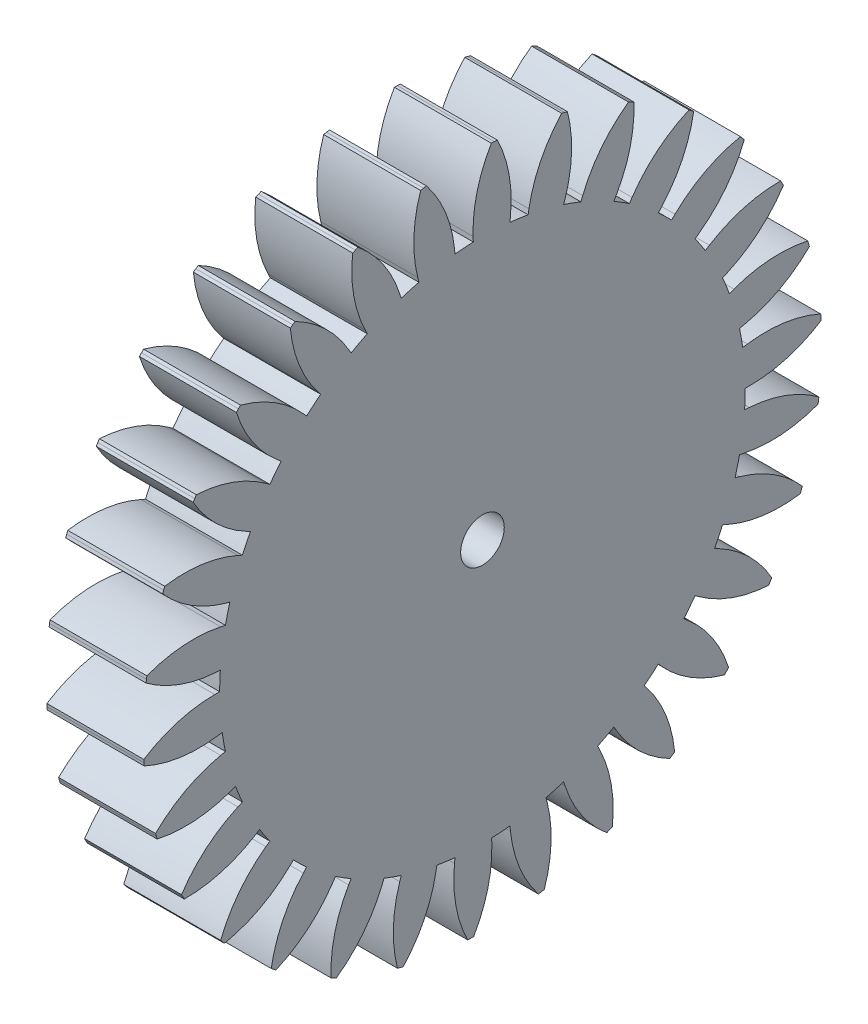
from build123d import *

# Parameters (mm, degrees)
SKETCH1_R           = 2.25
BOSS_EXTRUDE1_DEPTH = 10


with BuildPart() as part:
    # Sketch1 → Boss-Extrude1 (new body)
    with BuildSketch(Plane(origin=(0, 0, 0), x_dir=(0, 0, -1), z_dir=(1, 0, 0))):
        with BuildLine():
            Line((27.339383382, 3.842299761), (26.844249347, 3.77271321))
            ThreePointArc((26.844249347, 3.77271321), (26.696230764, 4.707265767), (26.515686935, 5.636083245))
            Line((26.515686935, 5.636083245), (27.004760736, 5.740039091))
            ThreePointArc((27.004760736, 5.740039091), (30.623978377, 7.066578698), (33.727065862, 9.353343163))
            Line((33.727065862, 9.353343163), (33.644159358, 9.647307454))
            Line((33.644159358, 9.647307454), (33.55869072, 9.940537065))
            ThreePointArc((33.55869072, 9.940537065), (29.715322743, 10.235437478), (25.943093221, 9.442513717))
            Line((25.943093221, 9.442513717), (25.47324691, 9.271503645))
            ThreePointArc((25.47324691, 9.271503645), (25.134158485, 10.154859192), (24.76444796, 11.025842608))
            Line((24.76444796, 11.025842608), (25.221220689, 11.229210929))
            ThreePointArc((25.221220689, 11.229210929), (28.485546649, 13.279240122), (31.045379161, 16.161201463))
            Line((31.045379161, 16.161201463), (30.90316575, 16.431504698))
            Line((30.90316575, 16.431504698), (30.758598943, 16.700556609))
            ThreePointArc((30.758598943, 16.700556609), (26.937904534, 16.189931607), (23.412965397, 14.630044514))
            Line((23.412965397, 14.630044514), (22.988941349, 14.365084882))
            ThreePointArc((22.988941349, 14.365084882), (22.473602874, 15.158636543), (21.930883777, 15.93371974))
            Line((21.930883777, 15.93371974), (22.335392274, 16.227612367))
            ThreePointArc((22.335392274, 16.227612367), (25.102159843, 18.911535033), (27.006860419, 22.26273771))
            Line((27.006860419, 22.26273771), (26.811555509, 22.497566339))
            Line((26.811555509, 22.497566339), (26.614208796, 22.730681692))
            ThreePointArc((26.614208796, 22.730681692), (22.983170634, 21.436848036), (19.859578637, 19.178172162))
            Line((19.859578637, 19.178172162), (19.499908737, 18.830842977))
            ThreePointArc((19.499908737, 18.830842977), (18.830842977, 19.499908737), (18.138834736, 20.145216862))
            Line((18.138834736, 20.145216862), (18.473400039, 20.516789275))
            ThreePointArc((18.473400039, 20.516789275), (20.621688199, 23.717305115), (21.788012282, 27.39128549))
            Line((21.788012282, 27.39128549), (21.548151636, 27.580376376))
            Line((21.548151636, 27.580376376), (21.306650015, 27.76736691))
            ThreePointArc((21.306650015, 27.76736691), (18.023961892, 25.74687134), (15.438232995, 22.888121661))
            Line((15.438232995, 22.888121661), (15.158636543, 22.473602874))
            ThreePointArc((15.158636543, 22.473602874), (14.365084882, 22.988941349), (13.554031577, 23.476271339))
            Line((13.554031577, 23.476271339), (13.804031577, 23.909284041))
            ThreePointArc((13.804031577, 23.909284041), (15.239949827, 27.486515155), (15.616923459, 31.322702656))
            Line((15.616923459, 31.322702656), (15.342990138, 31.45779162))
            Line((15.342990138, 31.45779162), (15.067888388, 31.590484952))
            ThreePointArc((15.067888388, 31.590484952), (12.277019527, 28.93163282), (10.342162489, 25.597750413))
            Line((10.342162489, 25.597750413), (10.154859192, 25.134158485))
            ThreePointArc((10.154859192, 25.134158485), (9.271503645, 25.47324691), (8.376852199, 25.781300107))
            Line((8.376852199, 25.781300107), (8.531360697, 26.256828365))
            ThreePointArc((8.531360697, 26.256828365), (9.192152518, 30.054432588), (8.763300142, 33.885167413))
            Line((8.763300142, 33.885167413), (8.467266346, 33.96035042))
            Line((8.467266346, 33.96035042), (8.170587735, 34.032947214))
            ThreePointArc((8.170587735, 34.032947214), (5.993512496, 30.851943116), (4.794089856, 27.18863464))
            Line((4.794089856, 27.18863464), (4.707265767, 26.696230764))
            ThreePointArc((4.707265767, 26.696230764), (3.77271321, 26.844249347), (2.833564184, 26.959562348))
            Line((2.833564184, 26.959562348), (2.885828415, 27.456823296))
            ThreePointArc((2.885828415, 27.456823296), (2.742614035, 31.3088271), (1.526678558, 34.966687755))
            Line((1.526678558, 34.966687755), (1.221482385, 34.978678946))
            Line((1.221482385, 34.978678946), (0.916193191, 34.988006374))
            ThreePointArc((0.916193191, 34.988006374), (-0.55193979, 31.423875454), (-0.963507509, 27.591245068))
            Line((-0.963507509, 27.591245068), (-0.946057761, 27.091549655))
            ThreePointArc((-0.946057761, 27.091549655), (-1.890962896, 27.042029275), (-2.833564184, 26.959562348))
            Line((-2.833564184, 26.959562348), (-2.885828415, 27.456823296))
            ThreePointArc((-2.885828415, 27.456823296), (-3.826789841, 31.194875631), (-5.776666205, 34.519996054))
            Line((-5.776666205, 34.519996054), (-6.077686218, 34.468271355))
            Line((-6.077686218, 34.468271355), (-6.378243392, 34.413921765))
            ThreePointArc((-6.378243392, 34.413921765), (-7.073269659, 30.622433646), (-6.678994972, 26.78798569))
            Line((-6.678994972, 26.78798569), (-6.558034024, 26.302837826))
            ThreePointArc((-6.558034024, 26.302837826), (-7.471994849, 26.057942762), (-8.376852199, 25.781300107))
            Line((-8.376852199, 25.781300107), (-8.531360697, 26.256828365))
            ThreePointArc((-8.531360697, 26.256828365), (-10.228944639, 29.717558407), (-12.827542935, 32.564614879))
            Line((-12.827542935, 32.564614879), (-13.11123077, 32.45143491))
            Line((-13.11123077, 32.45143491), (-13.393920133, 32.335783638))
            ThreePointArc((-13.393920133, 32.335783638), (-13.285463703, 28.482644546), (-12.102578306, 24.813962793))
            Line((-12.102578306, 24.813962793), (-11.883392732, 24.36456577))
            ThreePointArc((-11.883392732, 24.36456577), (-12.726464773, 23.934999109), (-13.554031577, 23.476271339))
            Line((-13.554031577, 23.476271339), (-13.804031577, 23.909284041))
            ThreePointArc((-13.804031577, 23.909284041), (-16.184045472, 26.94144128), (-19.317794486, 29.186003772))
            Line((-19.317794486, 29.186003772), (-19.571751621, 29.016315039))
            Line((-19.571751621, 29.016315039), (-19.824218292, 28.844416602))
            ThreePointArc((-19.824218292, 28.844416602), (-18.917019232, 25.098027203), (-16.997220893, 21.755450652))
            Line((-16.997220893, 21.755450652), (-16.689390155, 21.361445275))
            ThreePointArc((-16.689390155, 21.361445275), (-17.424727118, 20.765981143), (-18.138834736, 20.145216862))
            Line((-18.138834736, 20.145216862), (-18.473400039, 20.516789275))
            ThreePointArc((-18.473400039, 20.516789275), (-21.431825858, 22.98785389), (-24.96376572, 24.53182425))
            Line((-24.96376572, 24.53182425), (-25.176893012, 24.313042966))
            Line((-25.176893012, 24.313042966), (-25.388102985, 24.092410149))
            ThreePointArc((-25.388102985, 24.092410149), (-23.721810247, 20.616505638), (-21.149003365, 17.746120923))
            Line((-21.149003365, 17.746120923), (-20.765981143, 17.424727118))
            ThreePointArc((-20.765981143, 17.424727118), (-21.361445275, 16.689390155), (-21.930883777, 15.93371974))
            Line((-21.930883777, 15.93371974), (-22.335392274, 16.227612367))
            ThreePointArc((-22.335392274, 16.227612367), (-25.742932613, 18.029586977), (-29.518700603, 18.805486292))
            Line((-29.518700603, 18.805486292), (-29.681683365, 18.547174248))
            Line((-29.681683365, 18.547174248), (-29.842405752, 18.287449765))
            ThreePointArc((-29.842405752, 18.287449765), (-27.489844324, 15.233943848), (-24.376472906, 12.961200555))
            Line((-24.376472906, 12.961200555), (-23.934999109, 12.726464773))
            ThreePointArc((-23.934999109, 12.726464773), (-24.36456577, 11.883392732), (-24.76444796, 11.025842608))
            Line((-24.76444796, 11.025842608), (-25.221220689, 11.229210929))
            ThreePointArc((-25.221220689, 11.229210929), (-28.928949685, 12.283340598), (-32.783526624, 12.257258344))
            Line((-32.783526624, 12.257258344), (-32.889241728, 11.970705016))
            Line((-32.889241728, 11.970705016), (-32.992452188, 11.683240073))
            ThreePointArc((-32.992452188, 11.683240073), (-30.056440293, 9.185585611), (-26.53857361, 7.609813527))
            Line((-26.53857361, 7.609813527), (-26.057942762, 7.471994849))
            ThreePointArc((-26.057942762, 7.471994849), (-26.302837826, 6.558034024), (-26.515686935, 5.636083245))
            Line((-26.515686935, 5.636083245), (-27.004760736, 5.740039091))
            ThreePointArc((-27.004760736, 5.740039091), (-30.850632838, 6.000253292), (-34.615555218, 5.17332939))
            Line((-34.615555218, 5.17332939), (-34.659382406, 4.871058534))
            Line((-34.659382406, 4.871058534), (-34.700570148, 4.568416728))
            ThreePointArc((-34.700570148, 4.568416728), (-31.309425595, 2.735773205), (-27.5408113, 1.925841133))
            Line((-27.5408113, 1.925841133), (-27.042029275, 1.890962896))
            ThreePointArc((-27.042029275, 1.890962896), (-27.091549655, 0.946057761), (-27.108063155, 0))
            Line((-27.108063155, 0), (-27.608063155, 0))
            ThreePointArc((-27.608063155, 0), (-31.423995299, -0.545073875), (-34.934717945, -2.136698884))
            Line((-34.934717945, -2.136698884), (-34.914741759, -2.441476581))
            Line((-34.914741759, -2.441476581), (-34.892106681, -2.74606835))
            ThreePointArc((-34.892106681, -2.74606835), (-31.194038759, -3.833605617), (-27.339383382, -3.842299761))
            Line((-27.339383382, -3.842299761), (-26.844249347, -3.77271321))
            ThreePointArc((-26.844249347, -3.77271321), (-26.696230764, -4.707265767), (-26.515686935, -5.636083245))
            Line((-26.515686935, -5.636083245), (-27.004760736, -5.740039091))
            ThreePointArc((-27.004760736, -5.740039091), (-30.623978377, -7.066578698), (-33.727065862, -9.353343163))
            Line((-33.727065862, -9.353343163), (-33.644159358, -9.647307454))
            Line((-33.644159358, -9.647307454), (-33.55869072, -9.940537065))
            ThreePointArc((-33.55869072, -9.940537065), (-29.715322743, -10.235437478), (-25.943093221, -9.442513717))
            Line((-25.943093221, -9.442513717), (-25.47324691, -9.271503645))
            ThreePointArc((-25.47324691, -9.271503645), (-25.134158485, -10.154859192), (-24.76444796, -11.025842608))
            Line((-24.76444796, -11.025842608), (-25.221220689, -11.229210929))
            ThreePointArc((-25.221220689, -11.229210929), (-28.485546649, -13.279240122), (-31.045379161, -16.161201463))
            Line((-31.045379161, -16.161201463), (-30.90316575, -16.431504698))
            Line((-30.90316575, -16.431504698), (-30.758598943, -16.700556609))
            ThreePointArc((-30.758598943, -16.700556609), (-26.937904534, -16.189931607), (-23.412965397, -14.630044514))
            Line((-23.412965397, -14.630044514), (-22.988941349, -14.365084882))
            ThreePointArc((-22.988941349, -14.365084882), (-22.473602874, -15.158636543), (-21.930883777, -15.93371974))
            Line((-21.930883777, -15.93371974), (-22.335392274, -16.227612367))
            ThreePointArc((-22.335392274, -16.227612367), (-25.102159843, -18.911535033), (-27.006860419, -22.26273771))
            Line((-27.006860419, -22.26273771), (-26.811555509, -22.497566339))
            Line((-26.811555509, -22.497566339), (-26.614208796, -22.730681692))
            ThreePointArc((-26.614208796, -22.730681692), (-22.983170634, -21.436848036), (-19.859578637, -19.178172162))
            Line((-19.859578637, -19.178172162), (-19.499908737, -18.830842977))
            ThreePointArc((-19.499908737, -18.830842977), (-18.830842977, -19.499908737), (-18.138834736, -20.145216862))
            Line((-18.138834736, -20.145216862), (-18.473400039, -20.516789275))
            ThreePointArc((-18.473400039, -20.516789275), (-20.621688199, -23.717305115), (-21.788012282, -27.39128549))
            Line((-21.788012282, -27.39128549), (-21.548151636, -27.580376376))
            Line((-21.548151636, -27.580376376), (-21.306650015, -27.76736691))
            ThreePointArc((-21.306650015, -27.76736691), (-18.023961892, -25.74687134), (-15.438232995, -22.888121661))
            Line((-15.438232995, -22.888121661), (-15.158636543, -22.473602874))
            ThreePointArc((-15.158636543, -22.473602874), (-14.365084882, -22.988941349), (-13.554031577, -23.476271339))
            Line((-13.554031577, -23.476271339), (-13.804031577, -23.909284041))
            ThreePointArc((-13.804031577, -23.909284041), (-15.239949827, -27.486515155), (-15.616923459, -31.322702656))
            Line((-15.616923459, -31.322702656), (-15.342990138, -31.45779162))
            Line((-15.342990138, -31.45779162), (-15.067888388, -31.590484952))
            ThreePointArc((-15.067888388, -31.590484952), (-12.277019527, -28.93163282), (-10.342162489, -25.597750413))
            Line((-10.342162489, -25.597750413), (-10.154859192, -25.134158485))
            ThreePointArc((-10.154859192, -25.134158485), (-9.271503645, -25.47324691), (-8.376852199, -25.781300107))
            Line((-8.376852199, -25.781300107), (-8.531360697, -26.256828365))
            ThreePointArc((-8.531360697, -26.256828365), (-9.192152518, -30.054432588), (-8.763300142, -33.885167413))
            Line((-8.763300142, -33.885167413), (-8.467266346, -33.96035042))
            Line((-8.467266346, -33.96035042), (-8.170587735, -34.032947214))
            ThreePointArc((-8.170587735, -34.032947214), (-5.993512496, -30.851943116), (-4.794089856, -27.18863464))
            Line((-4.794089856, -27.18863464), (-4.707265767, -26.696230764))
            ThreePointArc((-4.707265767, -26.696230764), (-3.77271321, -26.844249347), (-2.833564184, -26.959562348))
            Line((-2.833564184, -26.959562348), (-2.885828415, -27.456823296))
            ThreePointArc((-2.885828415, -27.456823296), (-2.742614035, -31.3088271), (-1.526678558, -34.966687755))
            Line((-1.526678558, -34.966687755), (-1.221482385, -34.978678946))
            Line((-1.221482385, -34.978678946), (-0.916193191, -34.988006374))
            ThreePointArc((-0.916193191, -34.988006374), (0.55193979, -31.423875454), (0.963507509, -27.591245068))
            Line((0.963507509, -27.591245068), (0.946057761, -27.091549655))
            ThreePointArc((0.946057761, -27.091549655), (1.890962896, -27.042029275), (2.833564184, -26.959562348))
            Line((2.833564184, -26.959562348), (2.885828415, -27.456823296))
            ThreePointArc((2.885828415, -27.456823296), (3.826789841, -31.194875631), (5.776666205, -34.519996054))
            Line((5.776666205, -34.519996054), (6.077686218, -34.468271355))
            Line((6.077686218, -34.468271355), (6.378243392, -34.413921765))
            ThreePointArc((6.378243392, -34.413921765), (7.073269659, -30.622433646), (6.678994972, -26.78798569))
            Line((6.678994972, -26.78798569), (6.558034024, -26.302837826))
            ThreePointArc((6.558034024, -26.302837826), (7.471994849, -26.057942762), (8.376852199, -25.781300107))
            Line((8.376852199, -25.781300107), (8.531360697, -26.256828365))
            ThreePointArc((8.531360697, -26.256828365), (10.228944639, -29.717558407), (12.827542935, -32.564614879))
            Line((12.827542935, -32.564614879), (13.11123077, -32.45143491))
            Line((13.11123077, -32.45143491), (13.393920133, -32.335783638))
            ThreePointArc((13.393920133, -32.335783638), (13.285463703, -28.482644546), (12.102578306, -24.813962793))
            Line((12.102578306, -24.813962793), (11.883392732, -24.36456577))
            ThreePointArc((11.883392732, -24.36456577), (12.726464773, -23.934999109), (13.554031577, -23.476271339))
            Line((13.554031577, -23.476271339), (13.804031577, -23.909284041))
            ThreePointArc((13.804031577, -23.909284041), (16.184045472, -26.94144128), (19.317794486, -29.186003772))
            Line((19.317794486, -29.186003772), (19.571751621, -29.016315039))
            Line((19.571751621, -29.016315039), (19.824218292, -28.844416602))
            ThreePointArc((19.824218292, -28.844416602), (18.917019232, -25.098027203), (16.997220893, -21.755450652))
            Line((16.997220893, -21.755450652), (16.689390155, -21.361445275))
            ThreePointArc((16.689390155, -21.361445275), (17.424727118, -20.765981143), (18.138834736, -20.145216862))
            Line((18.138834736, -20.145216862), (18.473400039, -20.516789275))
            ThreePointArc((18.473400039, -20.516789275), (21.431825858, -22.98785389), (24.96376572, -24.53182425))
            Line((24.96376572, -24.53182425), (25.176893012, -24.313042966))
            Line((25.176893012, -24.313042966), (25.388102985, -24.092410149))
            ThreePointArc((25.388102985, -24.092410149), (23.721810247, -20.616505638), (21.149003365, -17.746120923))
            Line((21.149003365, -17.746120923), (20.765981143, -17.424727118))
            ThreePointArc((20.765981143, -17.424727118), (21.361445275, -16.689390155), (21.930883777, -15.93371974))
            Line((21.930883777, -15.93371974), (22.335392274, -16.227612367))
            ThreePointArc((22.335392274, -16.227612367), (25.742932613, -18.029586977), (29.518700603, -18.805486292))
            Line((29.518700603, -18.805486292), (29.681683365, -18.547174248))
            Line((29.681683365, -18.547174248), (29.842405752, -18.287449765))
            ThreePointArc((29.842405752, -18.287449765), (27.489844324, -15.233943848), (24.376472906, -12.961200555))
            Line((24.376472906, -12.961200555), (23.934999109, -12.726464773))
            ThreePointArc((23.934999109, -12.726464773), (24.36456577, -11.883392732), (24.76444796, -11.025842608))
            Line((24.76444796, -11.025842608), (25.221220689, -11.229210929))
            ThreePointArc((25.221220689, -11.229210929), (28.928949685, -12.283340598), (32.783526624, -12.257258344))
            Line((32.783526624, -12.257258344), (32.889241728, -11.970705016))
            Line((32.889241728, -11.970705016), (32.992452188, -11.683240073))
            ThreePointArc((32.992452188, -11.683240073), (30.056440293, -9.185585611), (26.53857361, -7.609813527))
            Line((26.53857361, -7.609813527), (26.057942762, -7.471994849))
            ThreePointArc((26.057942762, -7.471994849), (26.302837826, -6.558034024), (26.515686935, -5.636083245))
            Line((26.515686935, -5.636083245), (27.004760736, -5.740039091))
            ThreePointArc((27.004760736, -5.740039091), (30.850632838, -6.000253292), (34.615555218, -5.17332939))
            Line((34.615555218, -5.17332939), (34.659382406, -4.871058534))
            Line((34.659382406, -4.871058534), (34.700570148, -4.568416728))
            ThreePointArc((34.700570148, -4.568416728), (31.309425595, -2.735773205), (27.5408113, -1.925841133))
            Line((27.5408113, -1.925841133), (27.042029275, -1.890962896))
            ThreePointArc((27.042029275, -1.890962896), (27.091549655, -0.946057761), (27.108063155, 0))
            Line((27.108063155, 0), (27.608063155, 0))
            ThreePointArc((27.608063155, 0), (31.423995299, 0.545073875), (34.934717945, 2.136698884))
            Line((34.934717945, 2.136698884), (34.914741759, 2.441476581))
            Line((34.914741759, 2.441476581), (34.892106681, 2.74606835))
            ThreePointArc((34.892106681, 2.74606835), (31.194038759, 3.833605617), (27.339383382, 3.842299761))
        make_face()
        Circle(SKETCH1_R, mode=Mode.SUBTRACT)
    extrude(amount=BOSS_EXTRUDE1_DEPTH)


solid = part.part
